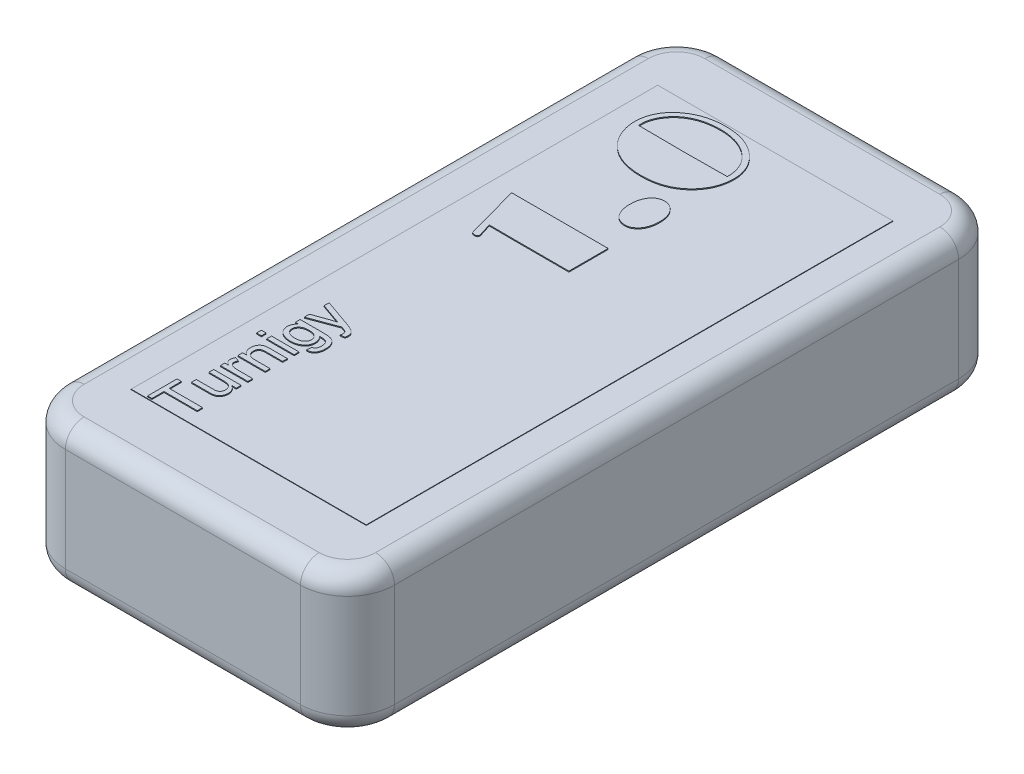
from build123d import *

# Parameters (mm, degrees)
SKETCH_1_W      = 35
SKETCH_1_H      = 70
EXTRUDE_1_DEPTH = 15
FILLET_1_R      = 5
FILLET_2_R      = 5
FILLET_3_R      = 5
FILLET_4_R      = 5
FILLET_5_R      = 2
FILLET_6_R      = 2
SKETCH_2_W      = 25
SKETCH_2_H      = 56
EXTRUDE_2_DEPTH = 0.05
SKETCH_3_W      = 0.512820513
SKETCH_3_H      = 0.512820512
SKETCH_3_W_2    = 2.923076923
EXTRUDE_3_DEPTH = 0.1


with BuildPart() as part:
    # Эскиз1 → Бобышка-Вытянуть1 (new body)
    with BuildSketch(Plane(origin=(0, 0, 0), x_dir=(1, 0, 0), z_dir=(0, 1, 0))):
        Rectangle(SKETCH_1_W, SKETCH_1_H)
    extrude(amount=EXTRUDE_1_DEPTH)

    # Скругление1
    fillet_1_edges = [part.edges().sort_by_distance(p)[0] for p in [
        (17.5, 7.5, 35),
    ]]
    fillet(fillet_1_edges, radius=FILLET_1_R)

    # Скругление2
    fillet_2_edges = [part.edges().sort_by_distance(p)[0] for p in [
        (-17.5, 7.5, 35),
    ]]
    fillet(fillet_2_edges, radius=FILLET_2_R)

    # Скругление3
    fillet_3_edges = [part.edges().sort_by_distance(p)[0] for p in [
        (17.5, 7.5, -35),
    ]]
    fillet(fillet_3_edges, radius=FILLET_3_R)

    # Скругление4
    fillet_4_edges = [part.edges().sort_by_distance(p)[0] for p in [
        (-17.5, 7.5, -35),
    ]]
    fillet(fillet_4_edges, radius=FILLET_4_R)

    # Скругление5
    fillet_5_edges = [part.edges().sort_by_distance(p)[0] for p in [
        (17.5, 15, 0),
        (16.035533906, 15, 33.535533906),
        (0, 15, 35),
        (-16.035533906, 15, 33.535533906),
        (0, 15, -35),
        (16.035533906, 15, -33.535533906),
        (-17.5, 15, 0),
        (-16.035533906, 15, -33.535533906),
    ]]
    fillet(fillet_5_edges, radius=FILLET_5_R)

    # Скругление6
    fillet_6_edges = [part.edges().sort_by_distance(p)[0] for p in [
        (17.5, 0, 0),
        (16.035533906, 0, 33.535533906),
        (0, 0, 35),
        (-16.035533906, 0, 33.535533906),
        (0, 0, -35),
        (16.035533906, 0, -33.535533906),
        (-17.5, 0, 0),
        (-16.035533906, 0, -33.535533906),
    ]]
    fillet(fillet_6_edges, radius=FILLET_6_R)


with BuildPart() as body_2:
    # Эскиз2 → Бобышка-Вытянуть2 (new body)
    with BuildSketch(Plane(origin=(0, 15, 0), x_dir=(1, 0, 0), z_dir=(0, 1, 0))):
        Rectangle(SKETCH_2_W, SKETCH_2_H)
    extrude(amount=EXTRUDE_2_DEPTH)

    # Эскиз3 → Бобышка-Вытянуть3 (add)
    with BuildSketch(Plane(origin=(0, 15.05, 0), x_dir=(1, 0, 0), z_dir=(0, 1, 0))):
        Polygon((-6.906891811, -26.564102564), (-10.445353349, -26.564102564), (-10.445353349, -27.846153846), (-10.906891811, -27.846153846), (-10.906891811, -24.717948718), (-10.445353349, -24.717948718), (-10.445353349, -26), (-6.906891811, -26), align=None)
        with BuildLine():
            Line((-6.906891811, -22.41025641), (-7.384455914, -22.41025641))
            add(Edge.make_bspline(
                [(-7.384455914, -22.41025641), (-7.342423438, -22.437958426), (-7.260983823, -22.491632199), (-7.152358589, -22.584528206), (-7.061084805, -22.685438877), (-6.985546325, -22.793363938), (-6.927189363, -22.909485017), (-6.885552956, -23.032688899), (-6.859724079, -23.163456871), (-6.857001058, -23.253084117), (-6.85560976, -23.298878205)],
                knots=[0, 0, 0, 0, 0.000150918, 0.000292409, 0.00042743, 0.000558127, 0.000686415, 0.000815898, 0.000947274, 0.001084527, 0.001084527, 0.001084527, 0.001084527], degree=3))
            add(Edge.make_bspline(
                [(-6.85560976, -23.298878205), (-6.856860901, -23.339550288), (-6.859335055, -23.419980079), (-6.878481219, -23.538400281), (-6.908613668, -23.653070359), (-6.951852071, -23.76119826), (-7.002862603, -23.861091088), (-7.062498917, -23.947978535), (-7.127532139, -24.022584293), (-7.200988427, -24.082480019), (-7.281584382, -24.131191743), (-7.369153092, -24.171978091), (-7.465247704, -24.205307576), (-7.533038124, -24.219998451), (-7.567949503, -24.227564103)],
                knots=[0, 0, 0, 0, 0.000121963, 0.000241185, 0.000358971, 0.000476966, 0.000589859, 0.000694762, 0.000792381, 0.000885743, 0.000977817, 0.001074245, 0.001175098, 0.001282185, 0.001282185, 0.001282185, 0.001282185], degree=3))
            add(Edge.make_bspline(
                [(-7.567949503, -24.227564103), (-7.595676863, -24.232241024), (-7.65778281, -24.242716765), (-7.762565618, -24.25005706), (-7.888122424, -24.255990915), (-7.978995424, -24.256263568), (-8.027885401, -24.256410256)],
                knots=[0, 0, 0, 0, 8.4314e-05, 0.000188853, 0.000314779, 0.000461422, 0.000461422, 0.000461422, 0.000461422], degree=3))
            Line((-8.027885401, -24.256410256), (-9.829968734, -24.256410256))
            Line((-9.829968734, -24.256410256), (-9.829968734, -23.743589744))
            Line((-9.829968734, -23.743589744), (-8.240225144, -23.743589744))
            add(Edge.make_bspline(
                [(-8.240225144, -23.743589744), (-8.209777033, -23.743286328), (-8.151551482, -23.742706111), (-8.067931276, -23.742445118), (-7.992069859, -23.739852807), (-7.92396541, -23.736614004), (-7.863764487, -23.73320299), (-7.811535276, -23.726877747), (-7.766667004, -23.722288704), (-7.739658665, -23.716547271), (-7.727404631, -23.713942308)],
                knots=[0, 0, 0, 0, 9.135e-05, 0.000174687, 0.000250847, 0.000319031, 0.00037926, 0.000431645, 0.000476866, 0.000514424, 0.000514424, 0.000514424, 0.000514424], degree=3))
            add(Edge.make_bspline(
                [(-7.727404631, -23.713942308), (-7.696804006, -23.705433319), (-7.637120952, -23.688837501), (-7.555967738, -23.645642565), (-7.484005463, -23.591935755), (-7.424452068, -23.52408183), (-7.376121795, -23.446239852), (-7.341464009, -23.358634743), (-7.321319248, -23.262392389), (-7.318570438, -23.195610301), (-7.317148221, -23.161057692)],
                knots=[0, 0, 0, 0, 9.5029e-05, 0.000185343, 0.000273967, 0.000363068, 0.00045446, 0.000547605, 0.000644255, 0.000747872, 0.000747872, 0.000747872, 0.000747872], degree=3))
            add(Edge.make_bspline(
                [(-7.317148221, -23.161057692), (-7.318607113, -23.125707559), (-7.32151704, -23.055197632), (-7.342779485, -22.951209334), (-7.37875052, -22.850959111), (-7.426949293, -22.755533367), (-7.487489298, -22.668343984), (-7.55878122, -22.592470189), (-7.642452317, -22.532931216), (-7.719183783, -22.493294931), (-7.786950086, -22.469419909), (-7.843396466, -22.453291969), (-7.905246158, -22.439906269), (-7.972578903, -22.42844387), (-8.045704111, -22.421179531), (-8.1239199, -22.414186671), (-8.207624885, -22.411590274), (-8.265065309, -22.410710495), (-8.294712324, -22.41025641)],
                knots=[0, 0, 0, 0, 0.000106015, 0.000211459, 0.000316888, 0.000424752, 0.000531226, 0.00063437, 0.000735344, 0.000837833, 0.000892326, 0.000950661, 0.001013845, 0.001082081, 0.001155437, 0.001234224, 0.001317619, 0.001406576, 0.001406576, 0.001406576, 0.001406576], degree=3))
            Line((-8.294712324, -22.41025641), (-9.829968734, -22.41025641))
            Line((-9.829968734, -22.41025641), (-9.829968734, -21.897435897))
            Line((-9.829968734, -21.897435897), (-6.906891811, -21.897435897))
            Line((-6.906891811, -21.897435897), (-6.906891811, -22.41025641))
        make_face()
        with BuildLine():
            Line((-6.906891811, -21.179487179), (-9.829968734, -21.179487179))
            Line((-9.829968734, -21.179487179), (-9.829968734, -20.717948718))
            Line((-9.829968734, -20.717948718), (-9.42211617, -20.717948718))
            add(Edge.make_bspline(
                [(-9.42211617, -20.717948718), (-9.465247005, -20.692125126), (-9.545152666, -20.644283455), (-9.650557605, -20.568927565), (-9.732898953, -20.496805814), (-9.792527043, -20.424870043), (-9.833402258, -20.352277423), (-9.860204133, -20.277907743), (-9.878271454, -20.20064328), (-9.880247832, -20.147806623), (-9.881250785, -20.12099359)],
                knots=[0, 0, 0, 0, 0.000150762, 0.000279308, 0.000388241, 0.00047822, 0.000558228, 0.000636819, 0.000714779, 0.000795103, 0.000795103, 0.000795103, 0.000795103], degree=3))
            add(Edge.make_bspline(
                [(-9.881250785, -20.12099359), (-9.879480229, -20.081320265), (-9.875891523, -20.000907176), (-9.848349746, -19.88042145), (-9.806592596, -19.758510191), (-9.765376794, -19.680862034), (-9.744231555, -19.641025641)],
                knots=[0, 0, 0, 0, 0.000118917, 0.00024103, 0.00036926, 0.000504357, 0.000504357, 0.000504357, 0.000504357], degree=3))
            Line((-9.744231555, -19.641025641), (-9.299520016, -19.801282051))
            add(Edge.make_bspline(
                [(-9.299520016, -19.801282051), (-9.318133069, -19.829058584), (-9.353970353, -19.88253909), (-9.390229531, -19.969142162), (-9.415883608, -20.054612817), (-9.418449984, -20.112535069), (-9.419712324, -20.141025641)],
                knots=[0, 0, 0, 0, 0.000100054, 0.000192643, 0.0002807, 0.000365942, 0.000365942, 0.000365942, 0.000365942], degree=3))
            add(Edge.make_bspline(
                [(-9.419712324, -20.141025641), (-9.418477935, -20.165723624), (-9.416040682, -20.214488875), (-9.39654604, -20.2854684), (-9.365956406, -20.3529172), (-9.322294476, -20.415374007), (-9.267542722, -20.471536439), (-9.202732445, -20.519963688), (-9.128174099, -20.55984625), (-9.073616132, -20.577992635), (-9.045513606, -20.587339744)],
                knots=[0, 0, 0, 0, 7.3996e-05, 0.000146103, 0.000219248, 0.000295264, 0.000373462, 0.00045359, 0.000537112, 0.000625834, 0.000625834, 0.000625834, 0.000625834], degree=3))
            add(Edge.make_bspline(
                [(-9.045513606, -20.587339744), (-9.000006221, -20.599566), (-8.907613003, -20.624388854), (-8.76384607, -20.648222837), (-8.613992445, -20.664337478), (-8.511905381, -20.665879342), (-8.459776426, -20.666666667)],
                knots=[0, 0, 0, 0, 0.000141285, 0.000286849, 0.000436663, 0.000592987, 0.000592987, 0.000592987, 0.000592987], degree=3))
            Line((-8.459776426, -20.666666667), (-6.906891811, -20.666666667))
            Line((-6.906891811, -20.666666667), (-6.906891811, -21.179487179))
        make_face()
        with BuildLine():
            Line((-6.906891811, -19.333333333), (-9.829968734, -19.333333333))
            Line((-9.829968734, -19.333333333), (-9.829968734, -18.820512821))
            Line((-9.829968734, -18.820512821), (-9.42211617, -18.820512821))
            add(Edge.make_bspline(
                [(-9.42211617, -18.820512821), (-9.458544766, -18.794072351), (-9.530009264, -18.742202253), (-9.624620669, -18.651953711), (-9.70351088, -18.552228496), (-9.769628602, -18.445128375), (-9.819151627, -18.328176599), (-9.855358263, -18.203169931), (-9.87734178, -18.069414269), (-9.879927641, -17.977380639), (-9.881250785, -17.930288462)],
                knots=[0, 0, 0, 0, 0.000134939, 0.00026472, 0.000390735, 0.000515514, 0.000641139, 0.000770466, 0.000905227, 0.001046437, 0.001046437, 0.001046437, 0.001046437], degree=3))
            add(Edge.make_bspline(
                [(-9.881250785, -17.930288462), (-9.880359787, -17.889075168), (-9.87859741, -17.807556021), (-9.859025184, -17.688533528), (-9.830694379, -17.5737964), (-9.789268957, -17.466131296), (-9.738268898, -17.367579407), (-9.681252058, -17.279670454), (-9.614515987, -17.206596317), (-9.540373888, -17.146484578), (-9.4588303, -17.097237671), (-9.37050268, -17.056731044), (-9.275327584, -17.02324856), (-9.208627715, -17.008396198), (-9.174520016, -17.000801282)],
                knots=[0, 0, 0, 0, 0.000123525, 0.00024433, 0.000360935, 0.000477603, 0.000589416, 0.000693422, 0.000790982, 0.000884964, 0.000978824, 0.001075977, 0.001176073, 0.001280824, 0.001280824, 0.001280824, 0.001280824], degree=3))
            add(Edge.make_bspline(
                [(-9.174520016, -17.000801282), (-9.161992125, -16.99848305), (-9.134926057, -16.99347459), (-9.090918422, -16.989515339), (-9.040776677, -16.984276491), (-8.984134669, -16.980225483), (-8.920777427, -16.978471567), (-8.851361448, -16.975406324), (-8.775478349, -16.975270937), (-8.722862851, -16.974672081), (-8.695353349, -16.974358974)],
                knots=[0, 0, 0, 0, 3.8202e-05, 8.2534e-05, 0.000132445, 0.000189477, 0.000252824, 0.000322577, 0.000397902, 0.000480438, 0.000480438, 0.000480438, 0.000480438], degree=3))
            Line((-8.695353349, -16.974358974), (-6.906891811, -16.974358974))
            Line((-6.906891811, -16.974358974), (-6.906891811, -17.487179487))
            Line((-6.906891811, -17.487179487), (-8.652084119, -17.487179487))
            add(Edge.make_bspline(
                [(-8.652084119, -17.487179487), (-8.698581457, -17.487632245), (-8.785302336, -17.48847667), (-8.906122253, -17.498631537), (-9.008546938, -17.515375731), (-9.094410925, -17.540139931), (-9.167529216, -17.573965019), (-9.230631251, -17.618871585), (-9.286790754, -17.674205535), (-9.334370111, -17.739830152), (-9.37307349, -17.813687891), (-9.400331377, -17.89480577), (-9.416471855, -17.981998439), (-9.4186151, -18.042131713), (-9.419712324, -18.072916667)],
                knots=[0, 0, 0, 0, 0.00013946, 0.000260103, 0.000363381, 0.000450338, 0.000527403, 0.000603878, 0.000681503, 0.000762919, 0.000846067, 0.0009307, 0.00101871, 0.001111028, 0.001111028, 0.001111028, 0.001111028], degree=3))
            add(Edge.make_bspline(
                [(-9.419712324, -18.072916667), (-9.419025845, -18.098042693), (-9.417677806, -18.147382657), (-9.409125875, -18.220233318), (-9.392603184, -18.290042607), (-9.37117604, -18.357414403), (-9.343740516, -18.42216677), (-9.309890218, -18.484139084), (-9.269495739, -18.543575688), (-9.22327201, -18.600777662), (-9.168427835, -18.654406794), (-9.100887854, -18.698808046), (-9.022910832, -18.73654363), (-8.934468526, -18.767603339), (-8.834795834, -18.791304539), (-8.724440312, -18.808628359), (-8.602872131, -18.81905341), (-8.51829164, -18.820012726), (-8.474199503, -18.820512821)],
                knots=[0, 0, 0, 0, 7.5389e-05, 0.000148041, 0.000219571, 0.00029027, 0.000359921, 0.000430202, 0.000501763, 0.000575224, 0.000650599, 0.000730828, 0.000816475, 0.000909992, 0.001011439, 0.001123412, 0.001244853, 0.001377104, 0.001377104, 0.001377104, 0.001377104], degree=3))
            Line((-8.474199503, -18.820512821), (-6.906891811, -18.820512821))
            Line((-6.906891811, -18.820512821), (-6.906891811, -19.333333333))
        make_face()
        with Locations((-10.650481555, -16)):
            Rectangle(SKETCH_3_W, SKETCH_3_H)
        with Locations((-8.368430273, -16)):
            Rectangle(SKETCH_3_W_2, SKETCH_3_H)
        with BuildLine():
            Line((-6.701763606, -15.16025641), (-6.650481555, -14.647435897))
            add(Edge.make_bspline(
                [(-6.650481555, -14.647435897), (-6.619410965, -14.641715316), (-6.559896455, -14.630757763), (-6.47975584, -14.595552951), (-6.41130279, -14.548664954), (-6.378426826, -14.506579664), (-6.362020016, -14.485576923)],
                knots=[0, 0, 0, 0, 9.4473e-05, 0.00018096, 0.000260787, 0.000340312, 0.000340312, 0.000340312, 0.000340312], degree=3))
            add(Edge.make_bspline(
                [(-6.362020016, -14.485576923), (-6.342784804, -14.45388484), (-6.302879741, -14.38813695), (-6.267387804, -14.272207664), (-6.243162714, -14.142064258), (-6.241238884, -14.049550402), (-6.240225144, -14.000801282)],
                knots=[0, 0, 0, 0, 0.000110826, 0.000229919, 0.000361001, 0.000507013, 0.000507013, 0.000507013, 0.000507013], degree=3))
            add(Edge.make_bspline(
                [(-6.240225144, -14.000801282), (-6.240462566, -13.974081932), (-6.240926104, -13.921915475), (-6.246537584, -13.846188627), (-6.256055467, -13.774976158), (-6.269773757, -13.708670687), (-6.286268154, -13.646627746), (-6.307128465, -13.589483397), (-6.331908976, -13.537056254), (-6.370202629, -13.47452572), (-6.426940489, -13.40572035), (-6.506055434, -13.334713932), (-6.600076717, -13.281595189), (-6.668481361, -13.258017615), (-6.70336617, -13.24599359)],
                knots=[0, 0, 0, 0, 8.0144e-05, 0.000156472, 0.000227638, 0.000295525, 0.000359477, 0.000420063, 0.000477766, 0.000533147, 0.000639646, 0.00074412, 0.000850365, 0.000960936, 0.000960936, 0.000960936, 0.000960936], degree=3))
            add(Edge.make_bspline(
                [(-6.70336617, -13.24599359), (-6.715876855, -13.242839916), (-6.743856108, -13.235786949), (-6.791419257, -13.229443099), (-6.848002116, -13.222753029), (-6.913807942, -13.218483045), (-6.988575331, -13.214199989), (-7.072744277, -13.21199019), (-7.166238726, -13.211407541), (-7.231678055, -13.211493535), (-7.26586617, -13.211538462)],
                knots=[0, 0, 0, 0, 3.8678e-05, 8.65e-05, 0.000143751, 0.000209632, 0.000284259, 0.000368428, 0.000462181, 0.000564746, 0.000564746, 0.000564746, 0.000564746], degree=3))
            add(Edge.make_bspline(
                [(-7.26586617, -13.211538462), (-7.237222986, -13.237929278), (-7.180964438, -13.289763914), (-7.108198022, -13.376216189), (-7.04540196, -13.466494297), (-6.994865822, -13.56238269), (-6.955276284, -13.663156846), (-6.927319842, -13.768811034), (-6.909970842, -13.879233527), (-6.907929195, -13.954529649), (-6.906891811, -13.992788462)],
                knots=[0, 0, 0, 0, 0.00011674, 0.000229291, 0.000338197, 0.000446088, 0.000553669, 0.000662319, 0.000773377, 0.000888097, 0.000888097, 0.000888097, 0.000888097], degree=3))
            add(Edge.make_bspline(
                [(-6.906891811, -13.992788462), (-6.907899068, -14.039888127), (-6.909866942, -14.131906555), (-6.93176252, -14.265581299), (-6.964684664, -14.391431789), (-7.01274959, -14.508905817), (-7.073592068, -14.618517254), (-7.148873741, -14.719195491), (-7.237436305, -14.811698451), (-7.338689819, -14.894594334), (-7.449144407, -14.968656895), (-7.565742747, -15.033699769), (-7.687608424, -15.089666046), (-7.815803489, -15.13289133), (-7.948331567, -15.168999017), (-8.086750602, -15.193161952), (-8.230234292, -15.209111653), (-8.327787522, -15.210722039), (-8.377244375, -15.211538462)],
                knots=[0, 0, 0, 0, 0.000141171, 0.000275806, 0.000405257, 0.000530693, 0.000655528, 0.000780369, 0.000906751, 0.00103879, 0.001172133, 0.001305218, 0.001438974, 0.001573785, 0.001710617, 0.001850658, 0.001994893, 0.002143208, 0.002143208, 0.002143208, 0.002143208], degree=3))
            add(Edge.make_bspline(
                [(-8.377244375, -15.211538462), (-8.44545445, -15.209996742), (-8.579766271, -15.206960956), (-8.776578405, -15.178463175), (-8.965737748, -15.134911047), (-9.116278012, -15.082589439), (-9.230829856, -15.032638218), (-9.311614741, -14.990925272), (-9.386652418, -14.944155001), (-9.457657361, -14.894588176), (-9.523472248, -14.840683831), (-9.584615586, -14.78315614), (-9.639993286, -14.720955717), (-9.690789057, -14.655362347), (-9.735239185, -14.5856111), (-9.775024413, -14.513370975), (-9.807965014, -14.437719491), (-9.834160059, -14.359014914), (-9.855139838, -14.277636758), (-9.870487699, -14.193322772), (-9.879225035, -14.105954221), (-9.880570441, -14.04676018), (-9.881250785, -14.016826923)],
                knots=[0, 0, 0, 0, 0.000204517, 0.000402712, 0.000595322, 0.000786137, 0.00087978, 0.000970094, 0.001058599, 0.001144855, 0.001229704, 0.00131359, 0.001396437, 0.001479295, 0.001562199, 0.00164431, 0.001726484, 0.001809342, 0.00189291, 0.001978411, 0.002066194, 0.002155995, 0.002155995, 0.002155995, 0.002155995], degree=3))
            add(Edge.make_bspline(
                [(-9.881250785, -14.016826923), (-9.880049554, -13.976952321), (-9.87768102, -13.898329388), (-9.858045756, -13.783418255), (-9.825775863, -13.6739246), (-9.780425937, -13.569873558), (-9.722749968, -13.470819409), (-9.6509402, -13.378171629), (-9.567629042, -13.290017526), (-9.503678935, -13.238082287), (-9.470994375, -13.211538462)],
                knots=[0, 0, 0, 0, 0.000119563, 0.000235749, 0.00034857, 0.000461255, 0.000575457, 0.000691488, 0.000812205, 0.000938402, 0.000938402, 0.000938402, 0.000938402], degree=3))
            Line((-9.470994375, -13.211538462), (-9.829968734, -13.211538462))
            Line((-9.829968734, -13.211538462), (-9.829968734, -12.698717949))
            Line((-9.829968734, -12.698717949), (-7.338782837, -12.698717949))
            add(Edge.make_bspline(
                [(-7.338782837, -12.698717949), (-7.284822738, -12.699199229), (-7.180869301, -12.700126409), (-7.030957876, -12.706606521), (-6.892993069, -12.716600188), (-6.767231993, -12.731388171), (-6.654215483, -12.751623229), (-6.553106439, -12.774417546), (-6.464035367, -12.801725937), (-6.38639619, -12.835530272), (-6.316526878, -12.873241837), (-6.252016925, -12.915796248), (-6.190365646, -12.962529023), (-6.132575881, -13.014647584), (-6.07894748, -13.072504298), (-6.029230222, -13.13544126), (-5.982577108, -13.202685862), (-5.940207283, -13.275094365), (-5.901574049, -13.351660173), (-5.868816461, -13.433268134), (-5.840658383, -13.518844372), (-5.818404368, -13.609183256), (-5.80084529, -13.70364064), (-5.788225684, -13.802353119), (-5.779761448, -13.905301078), (-5.779050038, -13.975409751), (-5.778686683, -14.011217949)],
                knots=[0, 0, 0, 0, 0.000161877, 0.000311854, 0.000450067, 0.000576786, 0.000691529, 0.00079435, 0.000887609, 0.000970517, 0.00104796, 0.001125523, 0.001202129, 0.001279853, 0.00135866, 0.001438499, 0.001520293, 0.001603984, 0.001689986, 0.00177733, 0.001867537, 0.001960043, 0.002056223, 0.002155611, 0.002258488, 0.002365887, 0.002365887, 0.002365887, 0.002365887], degree=3))
            add(Edge.make_bspline(
                [(-5.778686683, -14.011217949), (-5.779112325, -14.053451817), (-5.779946366, -14.136208559), (-5.792032264, -14.25706902), (-5.808569462, -14.371932685), (-5.835146102, -14.480103723), (-5.866435539, -14.582482736), (-5.905707634, -14.678756493), (-5.953706917, -14.767745595), (-6.006500111, -14.851293233), (-6.067662372, -14.926512137), (-6.136525053, -14.991601339), (-6.213199737, -15.046159964), (-6.29677574, -15.090178851), (-6.387729109, -15.124299887), (-6.486026434, -15.147109813), (-6.591623754, -15.160227738), (-6.664332282, -15.160246666), (-6.701763606, -15.16025641)],
                knots=[0, 0, 0, 0, 0.000126643, 0.000248156, 0.000364087, 0.000474478, 0.000581934, 0.000685053, 0.000785779, 0.000884909, 0.000981146, 0.001075809, 0.001168304, 0.001262573, 0.001358419, 0.0014589, 0.001564648, 0.001676853, 0.001676853, 0.001676853, 0.001676853], degree=3))
        make_face()
        with BuildLine():
            add(Edge.make_bspline(
                [(-8.412500785, -14.698717949), (-8.368668847, -14.698251438), (-8.283809775, -14.697348269), (-8.161364509, -14.686237911), (-8.047902522, -14.671205746), (-7.94404155, -14.647636352), (-7.848784364, -14.618534418), (-7.76310283, -14.581478437), (-7.68567666, -14.539158116), (-7.618320631, -14.489191083), (-7.559880744, -14.434057925), (-7.507692703, -14.376730513), (-7.465388087, -14.314184226), (-7.42977145, -14.249412224), (-7.402339988, -14.18103775), (-7.381845319, -14.109465914), (-7.37097511, -14.03398741), (-7.369284686, -13.982669202), (-7.368430273, -13.956730769)],
                knots=[0, 0, 0, 0, 0.000131449, 0.000254487, 0.000368599, 0.000474544, 0.000573634, 0.000666959, 0.000754126, 0.000837782, 0.000917722, 0.000994911, 0.001069813, 0.001143675, 0.001216287, 0.001290361, 0.001366512, 0.00144434, 0.00144434, 0.00144434, 0.00144434], degree=3))
            add(Edge.make_bspline(
                [(-7.368430273, -13.956730769), (-7.369276381, -13.930792131), (-7.370941758, -13.879737627), (-7.381813226, -13.804776847), (-7.40259861, -13.733567032), (-7.429775533, -13.665305242), (-7.464302706, -13.599563905), (-7.507885682, -13.538081579), (-7.559173298, -13.479833696), (-7.617445837, -13.424552358), (-7.683975904, -13.373523464), (-7.760268574, -13.330385995), (-7.844912719, -13.293573004), (-7.938227285, -13.263069517), (-8.04052878, -13.240268168), (-8.151382281, -13.223715837), (-8.270998297, -13.21299211), (-8.353715891, -13.212033827), (-8.396475144, -13.211538462)],
                knots=[0, 0, 0, 0, 7.7828e-05, 0.000153186, 0.000226489, 0.000299845, 0.000373328, 0.000448686, 0.000525346, 0.000605834, 0.000689329, 0.000776193, 0.000868048, 0.000965857, 0.001070239, 0.001182089, 0.001301933, 0.001430178, 0.001430178, 0.001430178, 0.001430178], degree=3))
            add(Edge.make_bspline(
                [(-8.396475144, -13.211538462), (-8.437631559, -13.212041968), (-8.517149302, -13.213014786), (-8.632818082, -13.223667622), (-8.740466532, -13.241025288), (-8.840817664, -13.264917023), (-8.932898617, -13.295902701), (-9.017400898, -13.334074773), (-9.094591801, -13.378321203), (-9.162673926, -13.430983656), (-9.22261733, -13.487799395), (-9.274940312, -13.547523086), (-9.320598407, -13.609084915), (-9.356784342, -13.674707785), (-9.384951477, -13.743018322), (-9.405118317, -13.814240679), (-9.417457867, -13.88819083), (-9.418955757, -13.938521089), (-9.419712324, -13.963942308)],
                knots=[0, 0, 0, 0, 0.000123439, 0.000238495, 0.000348095, 0.00045032, 0.000547623, 0.000639071, 0.000728125, 0.000813866, 0.000896619, 0.00097554, 0.001051831, 0.001126078, 0.001199735, 0.001273038, 0.001347729, 0.001423957, 0.001423957, 0.001423957, 0.001423957], degree=3))
            add(Edge.make_bspline(
                [(-9.419712324, -13.963942308), (-9.418963026, -13.989095825), (-9.417487447, -14.038630227), (-9.405184514, -14.111290766), (-9.384723081, -14.180681361), (-9.357687093, -14.248040266), (-9.321082861, -14.311818411), (-9.277796136, -14.373663835), (-9.224837478, -14.430920284), (-9.165934193, -14.486579848), (-9.098663695, -14.537347903), (-9.022630741, -14.580257353), (-8.939655346, -14.617613113), (-8.848649628, -14.646699594), (-8.750341806, -14.670049398), (-8.644507228, -14.686419563), (-8.531049342, -14.6972755), (-8.452859027, -14.698226887), (-8.412500785, -14.698717949)],
                knots=[0, 0, 0, 0, 7.5427e-05, 0.000148537, 0.0002203, 0.00029217, 0.000365718, 0.000440422, 0.000518147, 0.000599219, 0.000683353, 0.000770218, 0.000860606, 0.000955882, 0.001056362, 0.001163461, 0.001276921, 0.001397957, 0.001397957, 0.001397957, 0.001397957], degree=3))
        make_face(mode=Mode.SUBTRACT)
        with BuildLine():
            Line((-5.83637899, -11.948717949), (-6.283494375, -12))
            add(Edge.make_bspline(
                [(-6.283494375, -12), (-6.276771246, -11.976306223), (-6.263868803, -11.930835188), (-6.250224459, -11.863912505), (-6.241667549, -11.801775381), (-6.240689448, -11.7617761), (-6.240225144, -11.742788462)],
                knots=[0, 0, 0, 0, 7.3862e-05, 0.000141749, 0.00020476, 0.000261702, 0.000261702, 0.000261702, 0.000261702], degree=3))
            add(Edge.make_bspline(
                [(-6.240225144, -11.742788462), (-6.240717738, -11.719239356), (-6.24166355, -11.674023528), (-6.252096306, -11.610234022), (-6.268696901, -11.553302359), (-6.293348987, -11.503981504), (-6.323245771, -11.459949177), (-6.359455155, -11.42126832), (-6.399975641, -11.38541814), (-6.431145141, -11.366278913), (-6.446955914, -11.356570513)],
                knots=[0, 0, 0, 0, 7.0586e-05, 0.000135529, 0.000193321, 0.000247791, 0.000300243, 0.000352418, 0.000406391, 0.000461951, 0.000461951, 0.000461951, 0.000461951], degree=3))
            add(Edge.make_bspline(
                [(-6.446955914, -11.356570513), (-6.454144898, -11.352787468), (-6.470744352, -11.34405237), (-6.499185768, -11.330576939), (-6.534892719, -11.316239285), (-6.577353647, -11.300635613), (-6.626070445, -11.281548454), (-6.682389184, -11.263174064), (-6.744719262, -11.240785323), (-6.789047952, -11.226865483), (-6.812340529, -11.219551282)],
                knots=[0, 0, 0, 0, 2.437e-05, 5.6271e-05, 9.4363e-05, 0.000139754, 0.000191991, 0.000251286, 0.000317425, 0.000390658, 0.000390658, 0.000390658, 0.000390658], degree=3))
            add(Edge.make_bspline(
                [(-6.812340529, -11.219551282), (-6.829171602, -11.213954687), (-6.869005283, -11.200709366), (-6.908769221, -11.187256028), (-6.931731555, -11.179487179)],
                knots=[0, 0, 0, 0, 5.3211e-05, 0.000125934, 0.000125934, 0.000125934, 0.000125934], degree=3))
            Line((-6.931731555, -11.179487179), (-9.829968734, -12.256410256))
            Line((-9.829968734, -12.256410256), (-9.829968734, -11.713942308))
            Line((-9.829968734, -11.713942308), (-8.225000785, -11.140224359))
            add(Edge.make_bspline(
                [(-8.225000785, -11.140224359), (-8.12095052, -11.103735984), (-7.909399058, -11.029549062), (-7.693091764, -10.97064009), (-7.583173862, -10.940705128)],
                knots=[0, 0, 0, 0, 0.000330673, 0.000672314, 0.000672314, 0.000672314, 0.000672314], degree=3))
            add(Edge.make_bspline(
                [(-7.583173862, -10.940705128), (-7.622453962, -10.927132754), (-7.705088609, -10.898580169), (-7.834708028, -10.852636242), (-7.976722122, -10.803221983), (-8.075182018, -10.768222003), (-8.126443093, -10.75)],
                knots=[0, 0, 0, 0, 0.000124676, 0.000262284, 0.000412561, 0.000575771, 0.000575771, 0.000575771, 0.000575771], degree=3))
            Line((-8.126443093, -10.75), (-9.829968734, -10.153846154))
            Line((-9.829968734, -10.153846154), (-9.829968734, -9.613782051))
            Line((-9.829968734, -9.613782051), (-6.837981555, -10.661057692))
            add(Edge.make_bspline(
                [(-6.837981555, -10.661057692), (-6.801846322, -10.675021438), (-6.73253507, -10.7018054), (-6.63396341, -10.743427955), (-6.543414733, -10.780699181), (-6.461424521, -10.815680933), (-6.388869043, -10.849624438), (-6.324522256, -10.879838931), (-6.269082018, -10.907670313), (-6.235625305, -10.92643895), (-6.220193093, -10.935096154)],
                knots=[0, 0, 0, 0, 0.000116211, 0.000222905, 0.000320969, 0.00040998, 0.000490288, 0.000561255, 0.00062325, 0.000676328, 0.000676328, 0.000676328, 0.000676328], degree=3))
            add(Edge.make_bspline(
                [(-6.220193093, -10.935096154), (-6.184155083, -10.956761057), (-6.114842144, -10.998429788), (-6.022846331, -11.071075229), (-5.945687132, -11.148215751), (-5.883353118, -11.231067617), (-5.836208715, -11.321026828), (-5.802239483, -11.418386641), (-5.781980973, -11.524001771), (-5.779802994, -11.597132582), (-5.778686683, -11.634615385)],
                knots=[0, 0, 0, 0, 0.000126046, 0.000242428, 0.000350648, 0.000452572, 0.000552215, 0.000654088, 0.00076095, 0.000873313, 0.000873313, 0.000873313, 0.000873313], degree=3))
            add(Edge.make_bspline(
                [(-5.778686683, -11.634615385), (-5.779200614, -11.658702393), (-5.780262346, -11.708463834), (-5.792955622, -11.784895982), (-5.809746344, -11.866073537), (-5.827300379, -11.92054589), (-5.83637899, -11.948717949)],
                knots=[0, 0, 0, 0, 7.2187e-05, 0.000149131, 0.000231958, 0.00032068, 0.00032068, 0.00032068, 0.00032068], degree=3))
        make_face()
        with BuildLine():
            add(Edge.make_bspline(
                [(-10.277777778, 23.323350694), (-10.273376368, 23.478448603), (-10.264710007, 23.783835912), (-10.190551779, 24.231487016), (-10.072241949, 24.660485167), (-9.900156807, 25.067786318), (-9.685650692, 25.45790191), (-9.416013956, 25.822690944), (-9.10608503, 26.174473103), (-8.866142637, 26.382992828), (-8.743489583, 26.489583333)],
                knots=[0, 0, 0, 0, 0.000465023, 0.000915629, 0.001357405, 0.001797109, 0.00223912, 0.002689694, 0.003155385, 0.003642372, 0.003642372, 0.003642372, 0.003642372], degree=3))
            add(Edge.make_bspline(
                [(-8.743489583, 26.489583333), (-8.616455891, 26.588199728), (-8.362640906, 26.785236581), (-7.94957802, 27.038350407), (-7.509008097, 27.247562068), (-7.044271574, 27.423420978), (-6.552529459, 27.555941916), (-6.0363086, 27.654837738), (-5.493861284, 27.710788376), (-5.123822317, 27.718357661), (-4.934895833, 27.722222222)],
                knots=[0, 0, 0, 0, 0.000482206, 0.000963453, 0.001449744, 0.001943511, 0.002452083, 0.002975595, 0.003518898, 0.004085641, 0.004085641, 0.004085641, 0.004085641], degree=3))
            add(Edge.make_bspline(
                [(-4.934895833, 27.722222222), (-4.739353079, 27.718635284), (-4.355655615, 27.711596931), (-3.79460903, 27.639208736), (-3.260319068, 27.528059333), (-2.753116056, 27.369344817), (-2.274542344, 27.162120539), (-1.82275597, 26.911383413), (-1.397646253, 26.616384725), (-1.141998258, 26.384715635), (-1.013454861, 26.268229167)],
                knots=[0, 0, 0, 0, 0.000586339, 0.001150525, 0.001694053, 0.002221861, 0.002741902, 0.00325579, 0.003769944, 0.004289917, 0.004289917, 0.004289917, 0.004289917], degree=3))
            add(Edge.make_bspline(
                [(-1.013454861, 26.268229167), (-0.910794136, 26.165254817), (-0.708836944, 25.962680652), (-0.446312274, 25.630080517), (-0.220032042, 25.285144967), (-0.039602177, 24.921583785), (0.102486646, 24.544256956), (0.204991464, 24.150979233), (0.267250035, 23.742017097), (0.274243447, 23.463903687), (0.277777778, 23.323350694)],
                knots=[0, 0, 0, 0, 0.000435901, 0.000857517, 0.001268642, 0.001671406, 0.002072465, 0.002476187, 0.002888673, 0.003310133, 0.003310133, 0.003310133, 0.003310133], degree=3))
            add(Edge.make_bspline(
                [(0.277777778, 23.323350694), (0.276251908, 23.225633291), (0.273216274, 23.031229795), (0.244412735, 22.74180364), (0.195169926, 22.457553647), (0.134358452, 22.175952634), (0.047769491, 21.900595839), (-0.053677621, 21.628287386), (-0.175398557, 21.360989166), (-0.269492983, 21.188116248), (-0.316840278, 21.101128472)],
                knots=[0, 0, 0, 0, 0.000293097, 0.000583101, 0.000871371, 0.001158305, 0.001446615, 0.001736424, 0.002029715, 0.00232677, 0.00232677, 0.00232677, 0.00232677], degree=3))
            add(Edge.make_bspline(
                [(-0.316840278, 21.101128472), (-0.378009057, 20.999407231), (-0.499682184, 20.797069671), (-0.712977502, 20.51527309), (-0.942459513, 20.249546642), (-1.19295611, 20.003615541), (-1.463508848, 19.777358827), (-1.753439292, 19.56832595), (-2.06327704, 19.376284479), (-2.282801865, 19.266419807), (-2.393663194, 19.2109375)],
                knots=[0, 0, 0, 0, 0.000355863, 0.000707861, 0.001058592, 0.001408476, 0.00175969, 0.002115652, 0.002480035, 0.002851788, 0.002851788, 0.002851788, 0.002851788], degree=3))
            add(Edge.make_bspline(
                [(-2.393663194, 19.2109375), (-2.484936991, 19.168979379), (-2.669811969, 19.083993249), (-2.962404932, 18.981764641), (-3.267768693, 18.89178856), (-3.588058433, 18.822251813), (-3.920504222, 18.761107965), (-4.26802016, 18.724557935), (-4.629260916, 18.699517485), (-4.874808887, 18.696157508), (-5, 18.694444444)],
                knots=[0, 0, 0, 0, 0.000301212, 0.000610104, 0.000928768, 0.001255718, 0.001592879, 0.001942292, 0.002303325, 0.002678859, 0.002678859, 0.002678859, 0.002678859], degree=3))
            add(Edge.make_bspline(
                [(-5, 18.694444444), (-5.199856121, 18.698212458), (-5.590628854, 18.705579942), (-6.160489948, 18.774703451), (-6.698831946, 18.884224856), (-7.206045865, 19.038115695), (-7.681328826, 19.238904566), (-8.126568791, 19.482403465), (-8.540736683, 19.771680123), (-8.788512669, 19.998037697), (-8.912760417, 20.111545139)],
                knots=[0, 0, 0, 0, 0.000599351, 0.001171894, 0.001719225, 0.002245747, 0.00275924, 0.003264281, 0.003765814, 0.004270267, 0.004270267, 0.004270267, 0.004270267], degree=3))
            add(Edge.make_bspline(
                [(-8.912760417, 20.111545139), (-9.017248707, 20.218598401), (-9.224610551, 20.431050551), (-9.491771087, 20.788686184), (-9.728112194, 21.167672065), (-9.92164873, 21.574044301), (-10.078182679, 21.995807787), (-10.192180316, 22.430253978), (-10.260254391, 22.874182066), (-10.271927191, 23.173385387), (-10.277777778, 23.323350694)],
                knots=[0, 0, 0, 0, 0.000448343, 0.000889756, 0.00133603, 0.001786401, 0.002237502, 0.002683861, 0.003131651, 0.003581624, 0.003581624, 0.003581624, 0.003581624], degree=3))
        make_face()
        with BuildLine():
            Line((-9.70703125, 23.17578125), (-5.006510417, 23.138888889))
            Line((-5.006510417, 23.138888889), (-1.130642361, 23.167100694))
            Line((-1.130642361, 23.167100694), (-0.277777778, 23.17578125))
            add(Edge.make_bspline(
                [(-0.277777778, 23.17578125), (-0.278743017, 23.287274974), (-0.280640978, 23.506506504), (-0.316577625, 23.8295962), (-0.377030949, 24.141142507), (-0.463751438, 24.441276495), (-0.577194478, 24.729732746), (-0.717611342, 25.005375984), (-0.87872932, 25.273108727), (-1.008696717, 25.436938013), (-1.07421875, 25.51953125)],
                knots=[0, 0, 0, 0, 0.000334314, 0.000657366, 0.000973589, 0.001285395, 0.001593279, 0.001901905, 0.00221269, 0.002528667, 0.002528667, 0.002528667, 0.002528667], degree=3))
            add(Edge.make_bspline(
                [(-1.07421875, 25.51953125), (-1.189102678, 25.64772052), (-1.418595693, 25.903792389), (-1.818761462, 26.234527267), (-2.259704969, 26.51830807), (-2.7414654, 26.7513423), (-3.257041115, 26.939990229), (-3.806362478, 27.069740522), (-4.385448235, 27.153388682), (-4.781961309, 27.162172864), (-4.984809028, 27.166666667)],
                knots=[0, 0, 0, 0, 0.000515827, 0.00103042, 0.001551723, 0.002085529, 0.002632667, 0.003195335, 0.003776001, 0.004384197, 0.004384197, 0.004384197, 0.004384197], degree=3))
            add(Edge.make_bspline(
                [(-4.984809028, 27.166666667), (-5.16363738, 27.163744126), (-5.512037398, 27.158050325), (-6.020521372, 27.101853262), (-6.501088351, 27.014085347), (-6.954847814, 26.891053673), (-7.379380079, 26.730438886), (-7.775467592, 26.53345791), (-8.145007189, 26.302420161), (-8.367745397, 26.118826052), (-8.478732639, 26.02734375)],
                knots=[0, 0, 0, 0, 0.000536305, 0.00104485, 0.001532634, 0.002000665, 0.002453289, 0.002891963, 0.003326045, 0.003757161, 0.003757161, 0.003757161, 0.003757161], degree=3))
            add(Edge.make_bspline(
                [(-8.478732639, 26.02734375), (-8.571663506, 25.940844946), (-8.755917673, 25.76934364), (-8.999709685, 25.482263859), (-9.21364424, 25.174994744), (-9.394355824, 24.849840832), (-9.539470725, 24.515547517), (-9.645741925, 24.17921501), (-9.708034562, 23.843596869), (-9.717536032, 23.620175561), (-9.722222222, 23.509982639)],
                knots=[0, 0, 0, 0, 0.00038061, 0.000754637, 0.001127276, 0.001502258, 0.001868709, 0.002218768, 0.002558449, 0.002889023, 0.002889023, 0.002889023, 0.002889023], degree=3))
            add(Edge.make_bspline(
                [(-9.722222222, 23.509982639), (-9.721008577, 23.463676226), (-9.718086445, 23.352182829), (-9.711110111, 23.240865369), (-9.70703125, 23.17578125)],
                knots=[0, 0, 0, 0, 0.000138957, 0.00033457, 0.00033457, 0.00033457, 0.00033457], degree=3))
        make_face(mode=Mode.SUBTRACT)
        with BuildLine():
            add(Edge.make_bspline(
                [(-2.916666667, 15.430555556), (-2.915490825, 15.509451073), (-2.913189313, 15.663875791), (-2.893082387, 15.889239578), (-2.862101063, 16.102918339), (-2.812539956, 16.303087615), (-2.755665184, 16.49354069), (-2.680867378, 16.670558133), (-2.596617528, 16.837999548), (-2.496823654, 16.990821291), (-2.387341933, 17.129846679), (-2.266775095, 17.250320979), (-2.138003836, 17.353050496), (-2.000429904, 17.439354851), (-1.852448299, 17.504057787), (-1.695612837, 17.549821512), (-1.530327951, 17.579168703), (-1.41650373, 17.581927596), (-1.358506944, 17.583333333)],
                knots=[0, 0, 0, 0, 0.000236635, 0.000463173, 0.000678323, 0.000883605, 0.00108129, 0.001273932, 0.001459311, 0.001642902, 0.001820496, 0.001989293, 0.002152991, 0.002313787, 0.002475079, 0.002635758, 0.002803084, 0.002976912, 0.002976912, 0.002976912, 0.002976912], degree=3))
            add(Edge.make_bspline(
                [(-1.358506944, 17.583333333), (-1.299070185, 17.581936872), (-1.183098232, 17.57921212), (-1.013259276, 17.549835361), (-0.852570051, 17.501835187), (-0.698902765, 17.43684317), (-0.555258664, 17.351071704), (-0.419274889, 17.247646751), (-0.290674146, 17.126436784), (-0.175280299, 16.984746565), (-0.06829791, 16.830772054), (0.025167551, 16.663755812), (0.102004577, 16.484953406), (0.170115431, 16.296726445), (0.214259818, 16.094903941), (0.253016754, 15.883893939), (0.274663806, 15.661041431), (0.276721695, 15.508723284), (0.277777778, 15.430555556)],
                knots=[0, 0, 0, 0, 0.000178163, 0.000347628, 0.000515165, 0.000680438, 0.000846805, 0.001015644, 0.001192173, 0.00137556, 0.001562771, 0.001754162, 0.001948508, 0.002146169, 0.002353562, 0.002567274, 0.00278969, 0.003024155, 0.003024155, 0.003024155, 0.003024155], degree=3))
            add(Edge.make_bspline(
                [(0.277777778, 15.430555556), (0.275588336, 15.333551221), (0.271328937, 15.144836361), (0.241491574, 14.870903138), (0.189268445, 14.616080682), (0.118194373, 14.379251863), (0.024619327, 14.161749925), (-0.088477184, 13.962220364), (-0.223165621, 13.782250518), (-0.329185269, 13.678700392), (-0.381944444, 13.627170139)],
                knots=[0, 0, 0, 0, 0.000291001, 0.000566121, 0.000825314, 0.001070386, 0.001306613, 0.001534064, 0.001757155, 0.001978148, 0.001978148, 0.001978148, 0.001978148], degree=3))
            add(Edge.make_bspline(
                [(-0.381944444, 13.627170139), (-0.447461582, 13.573937897), (-0.576664167, 13.468961648), (-0.799468688, 13.357795498), (-1.038386748, 13.289688463), (-1.203249301, 13.281786726), (-1.286892361, 13.277777778)],
                knots=[0, 0, 0, 0, 0.000252605, 0.000498147, 0.000741396, 0.000991904, 0.000991904, 0.000991904, 0.000991904], degree=3))
            add(Edge.make_bspline(
                [(-1.286892361, 13.277777778), (-1.346330196, 13.279218035), (-1.463732526, 13.282062847), (-1.634742748, 13.311335289), (-1.796567632, 13.356471032), (-1.94899395, 13.420536207), (-2.091861428, 13.502901889), (-2.22609814, 13.604089436), (-2.349640808, 13.72449772), (-2.464256859, 13.861297711), (-2.568846469, 14.012459449), (-2.656997645, 14.179559038), (-2.735867272, 14.356572117), (-2.798778108, 14.547941166), (-2.848012991, 14.75124591), (-2.884604172, 14.966613911), (-2.909065384, 15.194204793), (-2.914082259, 15.350197179), (-2.916666667, 15.430555556)],
                knots=[0, 0, 0, 0, 0.000178163, 0.00035191, 0.000518841, 0.000681269, 0.000846541, 0.001012341, 0.001184234, 0.001362899, 0.001547092, 0.001734492, 0.001928838, 0.002127853, 0.002337863, 0.002555852, 0.002782805, 0.003023935, 0.003023935, 0.003023935, 0.003023935], degree=3))
        make_face()
        with BuildLine():
            Line((-10.277777778, 10.222222222), (-6.046006944, 10.222222222))
            Line((-6.046006944, 10.222222222), (-0.245225694, 10.222222222))
            Line((-0.245225694, 10.222222222), (0, 10.222222222))
            Line((0, 10.222222222), (0, 6.055555556))
            Line((0, 6.055555556), (-0.240885417, 6.055555556))
            Line((-0.240885417, 6.055555556), (-6.037326389, 6.055555556))
            Line((-6.037326389, 6.055555556), (-8.181423611, 6.068576389))
            Line((-8.181423611, 6.068576389), (-8.489583333, 6.068576389))
            Line((-8.489583333, 6.068576389), (-8.446180556, 5.925347222))
            Line((-8.446180556, 5.925347222), (-8.114149306, 4.879340278))
            add(Edge.make_bspline(
                [(-8.114149306, 4.879340278), (-8.097400185, 4.830620272), (-8.066846098, 4.741744247), (-8.059069282, 4.648177956), (-8.055555556, 4.605902778)],
                knots=[0, 0, 0, 0, 0.00015382, 0.000280601, 0.000280601, 0.000280601, 0.000280601], degree=3))
            add(Edge.make_bspline(
                [(-8.055555556, 4.605902778), (-8.058382875, 4.572595215), (-8.063839975, 4.508307211), (-8.137227104, 4.43312606), (-8.245622988, 4.392881508), (-8.329273363, 4.390334211), (-8.376736111, 4.388888889)],
                knots=[0, 0, 0, 0, 9.7463e-05, 0.000188117, 0.000296123, 0.000437782, 0.000437782, 0.000437782, 0.000437782], degree=3))
            add(Edge.make_bspline(
                [(-8.376736111, 4.388888889), (-8.412355692, 4.389660598), (-8.477891356, 4.391080448), (-8.565664541, 4.412582356), (-8.636127869, 4.446151812), (-8.686814506, 4.507552479), (-8.724671458, 4.601986597), (-8.768970101, 4.741326429), (-8.828190567, 4.932367579), (-8.865782172, 5.079508475), (-8.88671875, 5.161458333)],
                knots=[0, 0, 0, 0, 0.000106536, 0.000196013, 0.000269798, 0.000335943, 0.000429157, 0.000573272, 0.000775106, 0.001028827, 0.001028827, 0.001028827, 0.001028827], degree=3))
            Line((-8.88671875, 5.161458333), (-9.372829861, 6.993055556))
            Line((-9.372829861, 6.993055556), (-9.559461806, 7.676649306))
            Line((-9.559461806, 7.676649306), (-10.277777778, 10.222222222))
        make_face()
    extrude(amount=EXTRUDE_3_DEPTH)


solid = Compound([part.part, body_2.part])
